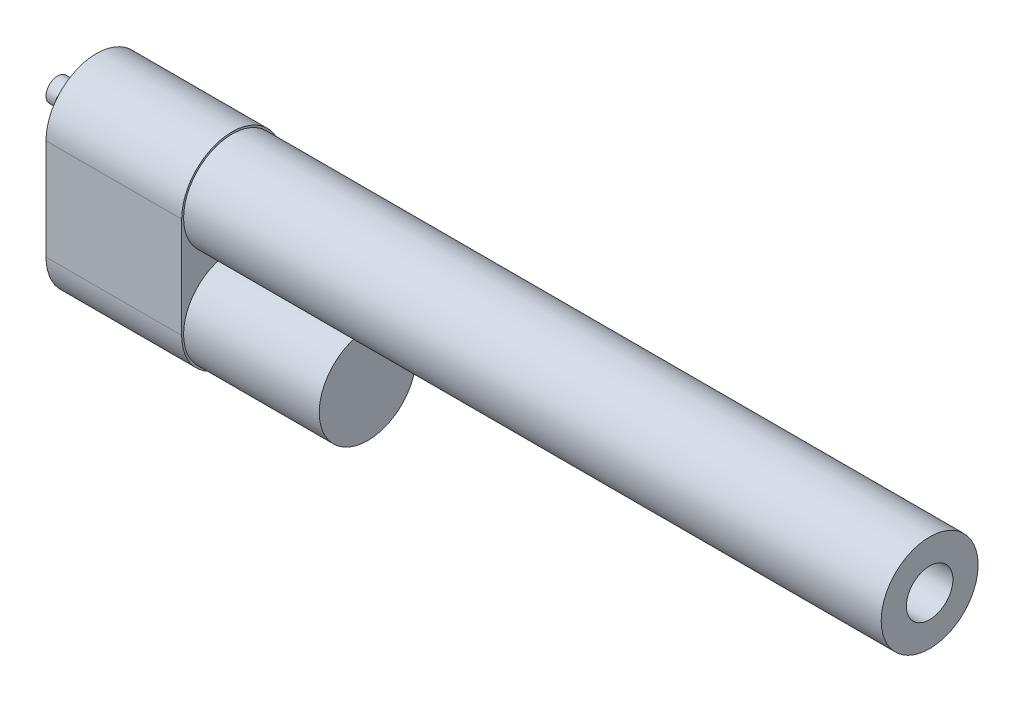
from build123d import *

# Parameters (mm, degrees)
SKETCH3_R               = 2.5
CUT_EXTRUDE2_DEPTH      = 13.5
CUT_EXTRUDE2_DEPTH_BACK = 13.5
SKETCH2_R               = 6
CUT_EXTRUDE3_DEPTH      = 183
SKETCH4_R               = 12.5
BOSS_EXTRUDE1_DEPTH     = 35
SKETCH5_R               = 12.5
BOSS_EXTRUDE2_DEPTH     = 35


with BuildPart() as part:
    # Sketch1 → Revolve1 (revolve)
    with BuildSketch(Plane.XY):
        Polygon((0, 0), (0, 3), (10, 3), (10, 12.5), (225, 12.5), (225, 0), align=None)
    revolve(axis=Axis((0, 0, 0), (1, 0, 0)))

    # Sketch3 → Cut-Extrude2 (cut, two sides)
    with BuildSketch(Plane.XY) as cut_extrude2_sk:
        with Locations((5, 0)):
            Circle(SKETCH3_R)
    extrude(amount=CUT_EXTRUDE2_DEPTH, mode=Mode.SUBTRACT)
    extrude(cut_extrude2_sk.sketch, amount=-CUT_EXTRUDE2_DEPTH_BACK, mode=Mode.SUBTRACT)

    # Sketch2 → Cut-Extrude3 (cut)
    with BuildSketch(Plane(origin=(225, 0, 0), x_dir=(0, 0, -1), z_dir=(1, 0, 0))):
        Circle(SKETCH2_R)
    extrude(amount=-CUT_EXTRUDE3_DEPTH, mode=Mode.SUBTRACT)

    # Sketch4 → Boss-Extrude1 (add)
    with BuildSketch(Plane.ZY.offset(-10)):
        with BuildLine():
            Line((-13, 0), (-13, -26))
            ThreePointArc((-13, -26), (0, -39), (13, -26))
            Line((13, -26), (13, 0))
            ThreePointArc((13, 0), (0, 13), (-13, 0))
        make_face()
        Circle(SKETCH4_R, mode=Mode.SUBTRACT)
    extrude(amount=-BOSS_EXTRUDE1_DEPTH)

    # Sketch5 → Boss-Extrude2 (add)
    with BuildSketch(Plane(origin=(45, 0, 0), x_dir=(0, 0, -1), z_dir=(1, 0, 0))):
        with Locations((0, -26)):
            Circle(SKETCH5_R)
    extrude(amount=BOSS_EXTRUDE2_DEPTH)


solid = part.part
